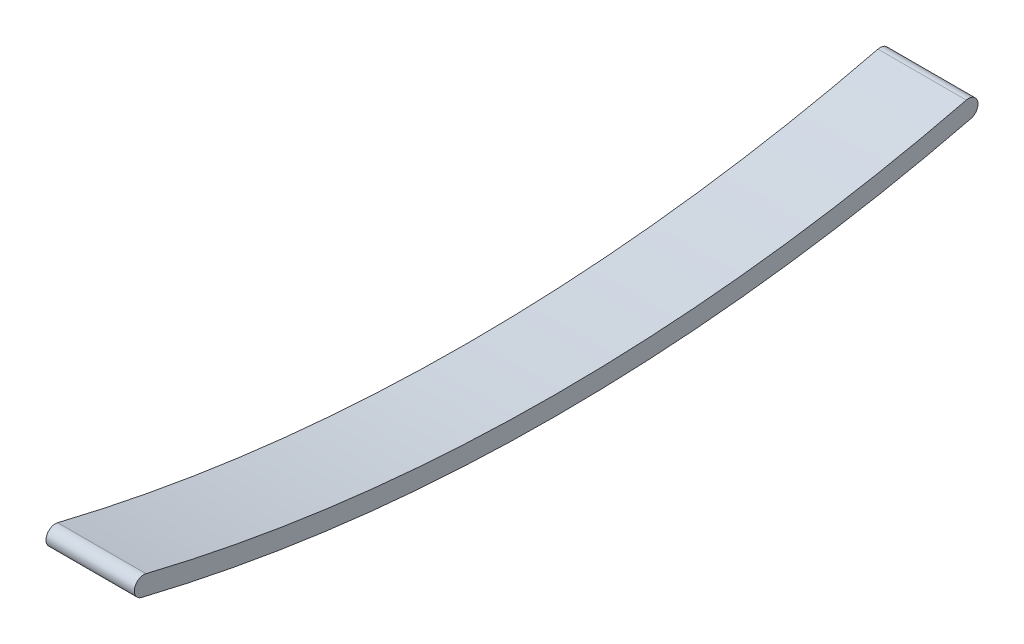
from build123d import *

# Parameters (mm, degrees)
BOSS_EXTRUDE1_DEPTH = 7


with BuildPart() as part:
    # Sketch1 → Boss-Extrude1 (new body)
    with BuildSketch(Plane(origin=(0, 0, 0), x_dir=(0, 0, -1), z_dir=(1, 0, 0))):
        with BuildLine():
            ThreePointArc((-32.5, -4.076092938), (0, -8), (32.5, -4.076092938))
            ThreePointArc((32.5, -4.076092938), (33.406949902, -4.626040094), (32.857002746, -5.532989996))
            ThreePointArc((32.857002746, -5.532989996), (0, -9.5), (-32.857002746, -5.532989996))
            ThreePointArc((-32.857002746, -5.532989996), (-33.406949902, -4.626040094), (-32.5, -4.076092938))
        make_face()
    extrude(amount=BOSS_EXTRUDE1_DEPTH)


solid = part.part
